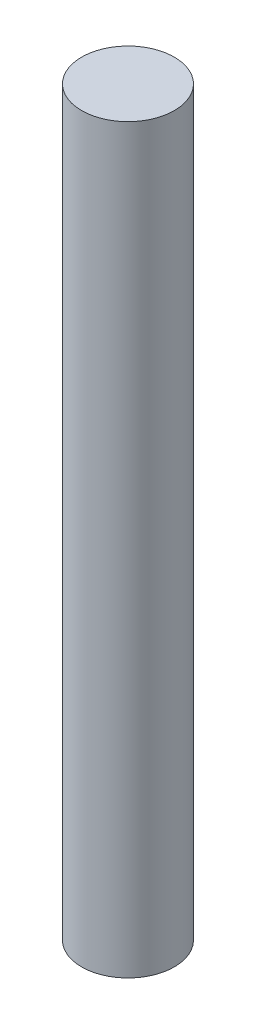
from build123d import *

# Parameters (mm, degrees)
SKETCH1_R           = 2.5
BOSS_EXTRUDE1_DEPTH = 40


with BuildPart() as part:
    # Sketch1 → Boss-Extrude1 (new body)
    with BuildSketch(Plane(origin=(0, 0, 0), x_dir=(1, 0, 0), z_dir=(0, 1, 0))):
        Circle(SKETCH1_R)
    extrude(amount=BOSS_EXTRUDE1_DEPTH)


solid = part.part
